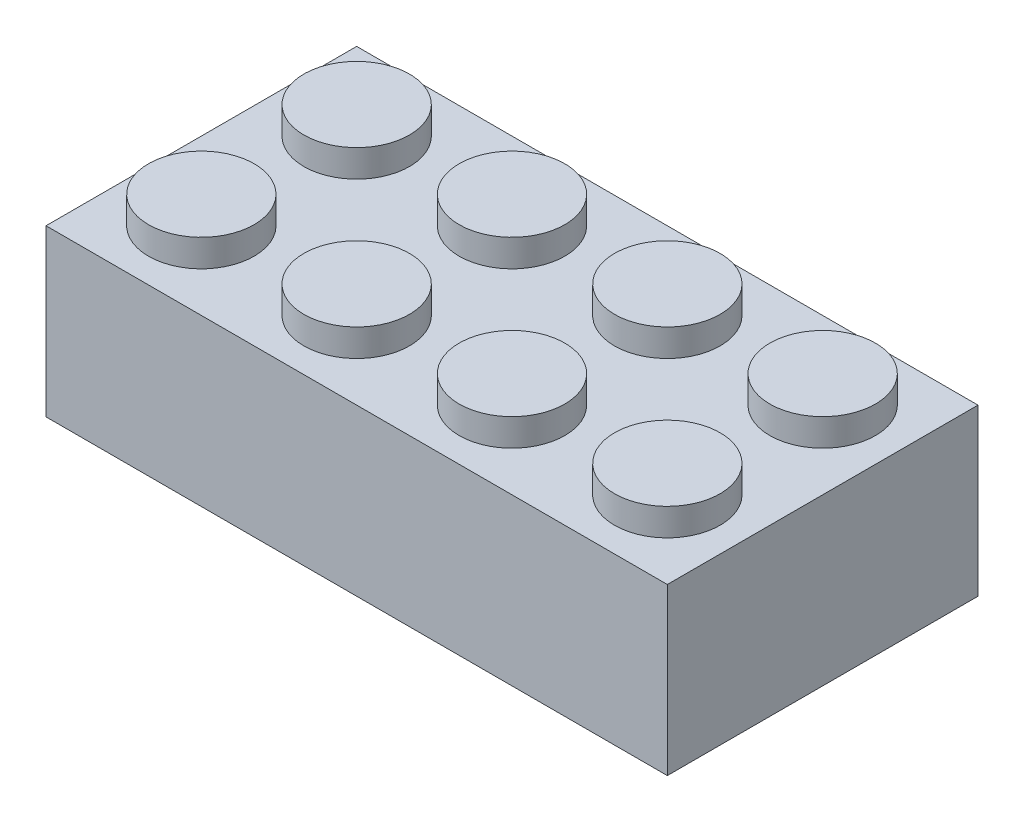
from build123d import *

# Parameters (mm, degrees)
SKETCH1_W            = 31.75
SKETCH1_H            = 15.875
BOSS_EXTRUDE1_DEPTH  = 4.2291
SKETCH2_W            = 29.21
SKETCH2_H            = 13.335
SKETCH2_R            = 3.175
SKETCH2_R_2          = 2.413
CUT_EXTRUDE1_DEPTH   = 7.1882
SKETCH3_R            = 2.69875
BOSS_EXTRUDE2_DEPTH  = 1.397
LPATTERN1_COUNT      = 4
LPATTERN1_PITCH      = 7.9375
LPATTERN1_COUNT_DIR2 = 2
LPATTERN1_PITCH_DIR2 = 7.9375
SKETCH2_3_R          = 3.175
SKETCH2_3_R_2        = 2.413
BOSS_EXTRUDE3_DEPTH  = 7.1882
LPATTERN2_COUNT      = 2
LPATTERN2_PITCH      = 7.9375
LPATTERN2_COL_COUNT  = 2
LPATTERN2_COL_PITCH  = 7.9375


with BuildPart() as part:
    # Sketch1 → Boss-Extrude1 (new, symmetric)
    with BuildSketch(Plane(origin=(0, 0, 0), x_dir=(1, 0, 0), z_dir=(0, 1, 0))):
        Rectangle(SKETCH1_W, SKETCH1_H)
    extrude(amount=BOSS_EXTRUDE1_DEPTH, both=True)

    # Sketch2 → Cut-Extrude1 (cut)
    with BuildSketch(Plane.XZ.offset(4.2291)):
        Rectangle(SKETCH2_W, SKETCH2_H)
        Circle(SKETCH2_R, mode=Mode.SUBTRACT)
        Circle(SKETCH2_R)
        Circle(SKETCH2_R_2, mode=Mode.SUBTRACT)
        Circle(SKETCH2_R_2)
    extrude(amount=-CUT_EXTRUDE1_DEPTH, mode=Mode.SUBTRACT)

    # Sketch3 → Boss-Extrude2 (add)
    with BuildSketch(Plane(origin=(0, 4.2291, 0), x_dir=(1, 0, 0), z_dir=(0, 1, 0))):
        with Locations(Location((11.90625, -3.96875, 0), (0, 0, 270))):
            Circle(SKETCH3_R)
    boss_extrude2 = extrude(amount=BOSS_EXTRUDE2_DEPTH)

    # LPattern1: Boss-Extrude2 4 × 2
    with Locations(*[(-i * LPATTERN1_PITCH, 0, -j * LPATTERN1_PITCH_DIR2) for i in range(LPATTERN1_COUNT) for j in range(LPATTERN1_COUNT_DIR2) if (i, j) != (0, 0)]):
        add(boss_extrude2)

    # Sketch2_3 → Boss-Extrude3 (add)
    with BuildSketch(Plane.XZ.offset(4.2291)):
        with Locations(Location((0, 0, 0), (0, 0, 270))):
            Circle(SKETCH2_3_R)
        with Locations(Location((0, 0, 0), (0, 0, 270))):
            Circle(SKETCH2_3_R_2, mode=Mode.SUBTRACT)
    boss_extrude3 = extrude(amount=-BOSS_EXTRUDE3_DEPTH)

    # LPattern2: Boss-Extrude3 ×2
    with Locations(*[(i * LPATTERN2_PITCH, 0, 0) for i in range(1, LPATTERN2_COUNT)]):
        add(boss_extrude3)

    # LPattern2 col: Boss-Extrude3 ×2
    with Locations(*[(-i * LPATTERN2_COL_PITCH, 0, 0) for i in range(1, LPATTERN2_COL_COUNT)]):
        add(boss_extrude3)


solid = part.part
